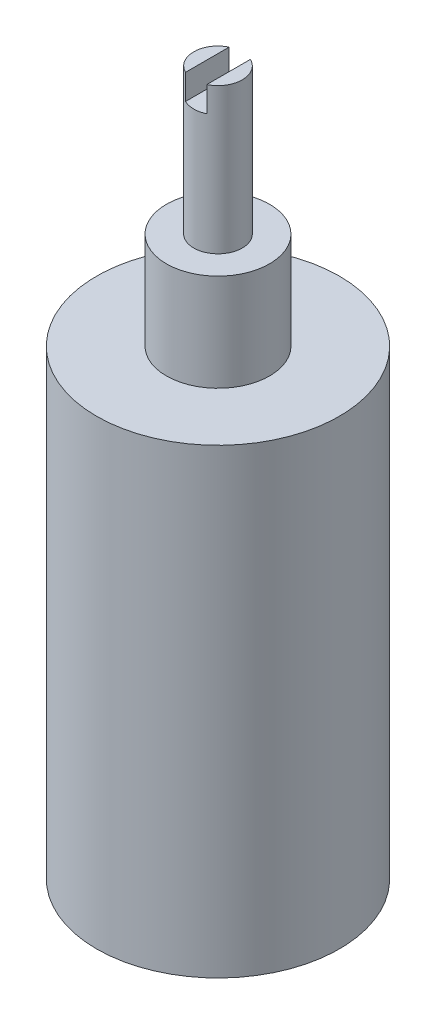
from build123d import *

# Parameters (mm, degrees)
SKETCH1_R               = 10
BOSS_EXTRUDE1_DEPTH     = 19
SKETCH2_R               = 4.25
BOSS_EXTRUDE2_DEPTH     = 8
SKETCH3_R               = 2
BOSS_EXTRUDE3_DEPTH     = 12
SKETCH4_W               = 1.75006174
SKETCH4_H               = 4.164275762
CUT_EXTRUDE1_DEPTH      = 11
CUT_EXTRUDE1_DEPTH_BACK = 11


with BuildPart() as part:
    # Sketch1 → Boss-Extrude1 (new body, symmetric)
    with BuildSketch(Plane(origin=(0, 0, 0), x_dir=(1, 0, 0), z_dir=(0, 1, 0))):
        Circle(SKETCH1_R)
    extrude(amount=BOSS_EXTRUDE1_DEPTH, both=True)

    # Sketch2 → Boss-Extrude2 (add)
    with BuildSketch(Plane(origin=(0, 19, 0), x_dir=(1, 0, 0), z_dir=(0, 1, 0))):
        Circle(SKETCH2_R)
    extrude(amount=BOSS_EXTRUDE2_DEPTH)

    # Sketch3 → Boss-Extrude3 (add)
    with BuildSketch(Plane(origin=(0, 27, 0), x_dir=(1, 0, 0), z_dir=(0, 1, 0))):
        Circle(SKETCH3_R)
    extrude(amount=BOSS_EXTRUDE3_DEPTH)

    # Sketch4 → Cut-Extrude1 (cut, two sides)
    with BuildSketch(Plane.XY) as cut_extrude1_sk:
        with Locations((0, 39)):
            Rectangle(SKETCH4_W, SKETCH4_H)
    extrude(amount=CUT_EXTRUDE1_DEPTH, mode=Mode.SUBTRACT)
    extrude(cut_extrude1_sk.sketch, amount=-CUT_EXTRUDE1_DEPTH_BACK, mode=Mode.SUBTRACT)


solid = part.part
